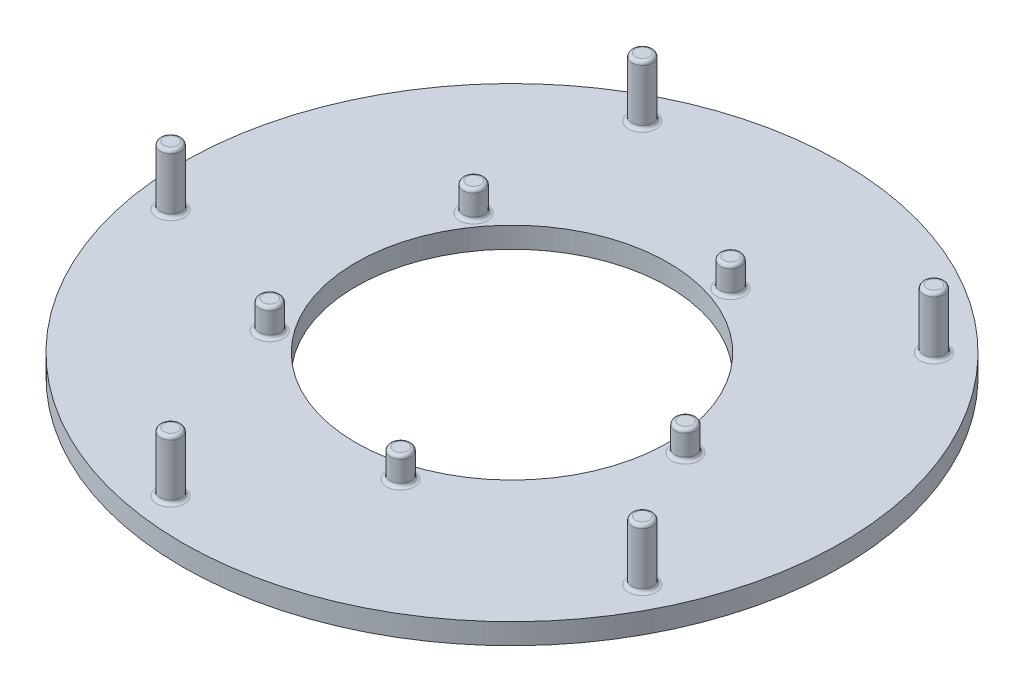
from build123d import *

# Parameters (mm, degrees)
SKETCH1_R                = 47.5
SKETCH1_R_2              = 22.5
BOSS_EXTRUDE1_DEPTH      = 3
SKETCH2_R                = 1.5
BOSS_EXTRUDE2_DEPTH      = 4
FILLET1_R                = 0.5
SKETCH3_R                = 1.5
BOSS_EXTRUDE3_DEPTH      = 4.5
FILLET2_R                = 0.5
CIRPATTERN1_COUNT        = 5
FILLET1_OF_CIRPATTERN1_R = 0.5
FILLET2_OF_CIRPATTERN1_R = 0.5


with BuildPart() as part:
    # Sketch1 → Boss-Extrude1 (new body)
    with BuildSketch(Plane(origin=(0, 0, 0), x_dir=(1, 0, 0), z_dir=(0, 1, 0))):
        Circle(SKETCH1_R)
        Circle(SKETCH1_R_2, mode=Mode.SUBTRACT)
    extrude(amount=BOSS_EXTRUDE1_DEPTH)

    # Sketch2 → Boss-Extrude2 (add)
    with BuildSketch(Plane(origin=(0, 3, 0), x_dir=(1, 0, 0), z_dir=(0, 1, 0))):
        with Locations((25, 0)):
            Circle(SKETCH2_R)
        with Locations((30.405591591, 30.405591591)):
            Circle(SKETCH2_R)
    boss_extrude2 = extrude(amount=BOSS_EXTRUDE2_DEPTH)

    # Fillet1
    fillet1_edges = [part.edges().sort_by_distance(p)[0] for p in [
        (23.5, 3, 0),
        (23.5, 7, 0),
        (28.905591591, 3, -30.405591591),
    ]]
    fillet(fillet1_edges, radius=FILLET1_R)

    # Sketch3 → Boss-Extrude3 (add)
    with BuildSketch(Plane(origin=(0, 7, 0), x_dir=(1, 0, 0), z_dir=(0, 1, 0))):
        with Locations((30.405591591, 30.405591591)):
            Circle(SKETCH3_R)
    boss_extrude3 = extrude(amount=BOSS_EXTRUDE3_DEPTH)

    # Fillet2
    fillet2_edges = [part.edges().sort_by_distance(p)[0] for p in [
        (28.905591591, 11.5, -30.405591591),
    ]]
    fillet(fillet2_edges, radius=FILLET2_R)

    # CirPattern1: Boss-Extrude2, Boss-Extrude3 ×5 about axis
    cirpattern1_axis = Axis((0, 0, 0), (0, 1, 0))
    for i in range(1, CIRPATTERN1_COUNT):
        add(boss_extrude2.rotate(cirpattern1_axis, i * 360 / CIRPATTERN1_COUNT))
        add(boss_extrude3.rotate(cirpattern1_axis, i * 360 / CIRPATTERN1_COUNT))

    # Fillet1 of CirPattern1
    fillet1_of_cirpattern1_edges = [part.edges().sort_by_distance(p)[0] for p in [
        (7.261899368, 3, -22.349828133),
        (7.261899368, 7, -22.349828133),
        (-19.98511698, 3, -36.886695766),
        (-19.011899368, 3, -13.812953429),
        (-19.011899368, 7, -13.812953429),
        (-41.257073154, 3, 7.608359875),
        (-19.011899368, 3, 13.812953429),
        (-19.011899368, 7, 13.812953429),
        (-5.513156505, 3, 41.588920767),
        (7.261899368, 3, 22.349828133),
        (7.261899368, 7, 22.349828133),
        (37.849755049, 3, 18.095006714),
    ]]
    fillet(fillet1_of_cirpattern1_edges, radius=FILLET1_OF_CIRPATTERN1_R)

    # Fillet2 of CirPattern1
    fillet2_of_cirpattern1_edges = [part.edges().sort_by_distance(p)[0] for p in [
        (-19.98511698, 11.5, -36.886695766),
        (-41.257073154, 11.5, 7.608359875),
        (-5.513156505, 11.5, 41.588920767),
        (37.849755049, 11.5, 18.095006714),
    ]]
    fillet(fillet2_of_cirpattern1_edges, radius=FILLET2_OF_CIRPATTERN1_R)


solid = part.part
